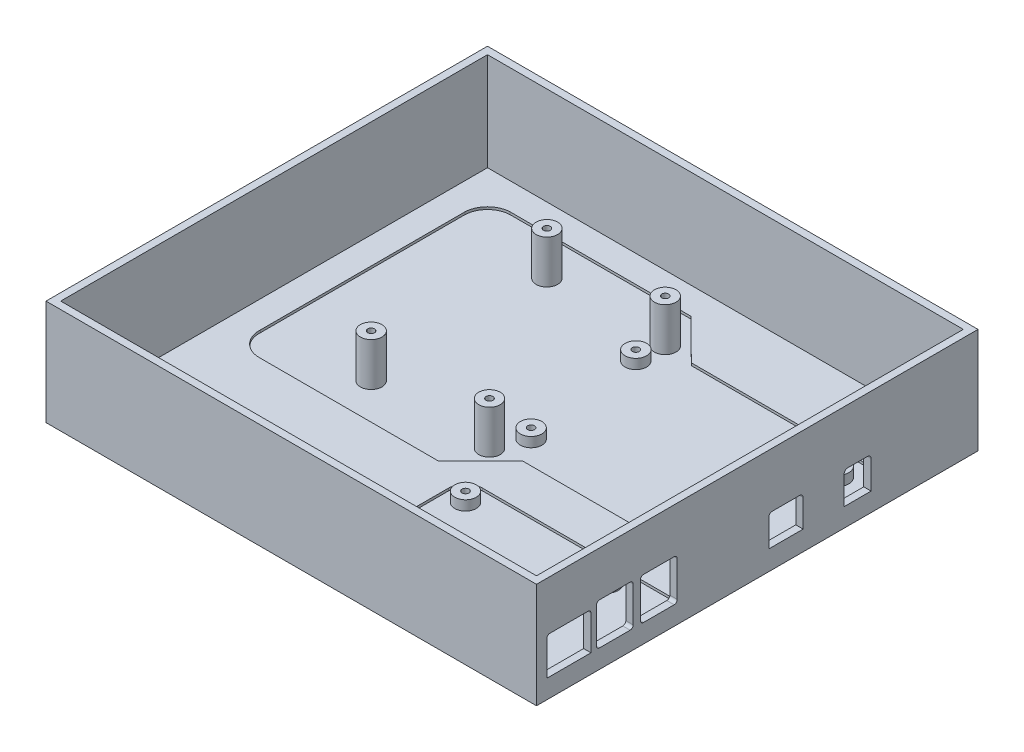
from build123d import *

# Parameters (mm, degrees)
SKETCH1_W           = 200.4
SKETCH1_H           = 180.383316975
SKETCH1_W_2         = 194.4
SKETCH1_H_2         = 174.383316975
BOSS_EXTRUDE1_DEPTH = 3
SKETCH1_3_W         = 200.4
SKETCH1_3_H         = 180.383316975
SKETCH1_3_W_2       = 194.4
SKETCH1_3_H_2       = 174.383316975
BOSS_EXTRUDE2_DEPTH = 40
SKETCH2_R           = 4.4
SKETCH2_R_2         = 1.4
BOSS_EXTRUDE3_DEPTH = 3
BOSS_EXTRUDE4_START = 3
SKETCH2_2_R         = 4.4
SKETCH2_2_R_2       = 1.4
BOSS_EXTRUDE4_DEPTH = 13.67
SKETCH3_R           = 4.4
CUT_EXTRUDE1_DEPTH  = 1
CUT_EXTRUDE2_DEPTH  = 5


with BuildPart() as part:
    # Sketch1 → Boss-Extrude1 (new body)
    with BuildSketch(Plane(origin=(0, -4, 0), x_dir=(-1, 0, 0), z_dir=(0, -1, 0))):
        with Locations((47.125, -25.608341513)):
            Rectangle(SKETCH1_W, SKETCH1_H)
        with Locations((47.125, -25.608341513)):
            Rectangle(SKETCH1_W_2, SKETCH1_H_2, mode=Mode.SUBTRACT)
        with Locations((47.125, -25.608341513)):
            Rectangle(SKETCH1_W_2, SKETCH1_H_2)
    extrude(amount=BOSS_EXTRUDE1_DEPTH)

    # Sketch1_3 → Boss-Extrude2 (add)
    with BuildSketch(Plane(origin=(0, -4, 0), x_dir=(-1, 0, 0), z_dir=(0, -1, 0))):
        with Locations((47.125, -25.608341513)):
            Rectangle(SKETCH1_3_W, SKETCH1_3_H)
        with Locations((47.125, -25.608341513)):
            Rectangle(SKETCH1_3_W_2, SKETCH1_3_H_2, mode=Mode.SUBTRACT)
    extrude(amount=-BOSS_EXTRUDE2_DEPTH)

    # Sketch2 → Boss-Extrude3 (add)
    with BuildSketch(Plane(origin=(0, -4, 0), x_dir=(1, 0, 0), z_dir=(0, 1, 0))):
        with Locations(Location((-94.083642028, 35.599553337, 0), (0, 0, 90))):
            Circle(SKETCH2_R)
        with Locations(Location((-94.083642028, 35.599553337, 0), (0, 0, 270))):
            Circle(SKETCH2_R_2, mode=Mode.SUBTRACT)
        with Locations(Location((-45.977533902, 35.843746779, 0), (0, 0, 90))):
            Circle(SKETCH2_R)
        with Locations(Location((-45.977533902, 35.843746779, 0), (0, 0, 270))):
            Circle(SKETCH2_R_2, mode=Mode.SUBTRACT)
        with Locations(Location((-46.675, 24.55, 0), (0, 0, 90))):
            Circle(SKETCH2_R)
        with Locations(Location((-46.675, 24.55, 0), (0, 0, 270))):
            Circle(SKETCH2_R_2, mode=Mode.SUBTRACT)
        with Locations(Location((35.975, 24.55, 0), (0, 0, 90))):
            Circle(SKETCH2_R)
        with Locations(Location((35.975, 24.55, 0), (0, 0, 270))):
            Circle(SKETCH2_R_2, mode=Mode.SUBTRACT)
        with Locations(Location((-40.425, -24.5, 0), (0, 0, 90))):
            Circle(SKETCH2_R)
        with Locations(Location((-40.425, -24.5, 0), (0, 0, 270))):
            Circle(SKETCH2_R_2, mode=Mode.SUBTRACT)
        with Locations(Location((-93.717351865, -36.559608852, 0), (0, 0, 90))):
            Circle(SKETCH2_R)
        with Locations(Location((-93.717351865, -36.559608852, 0), (0, 0, 270))):
            Circle(SKETCH2_R_2, mode=Mode.SUBTRACT)
        with Locations(Location((-45.611243739, -36.31541541, 0), (0, 0, 90))):
            Circle(SKETCH2_R)
        with Locations(Location((-45.611243739, -36.31541541, 0), (0, 0, 270))):
            Circle(SKETCH2_R_2, mode=Mode.SUBTRACT)
        with Locations(Location((34.775, -24.5, 0), (0, 0, 90))):
            Circle(SKETCH2_R)
        with Locations(Location((34.775, -24.5, 0), (0, 0, 270))):
            Circle(SKETCH2_R_2, mode=Mode.SUBTRACT)
        with Locations(Location((-31.425, -60.3, 0), (0, 0, 90))):
            Circle(SKETCH2_R)
        with Locations(Location((-31.425, -60.3, 0), (0, 0, 270))):
            Circle(SKETCH2_R_2, mode=Mode.SUBTRACT)
        with Locations(Location((26.575, -60.3, 0), (0, 0, 90))):
            Circle(SKETCH2_R)
        with Locations(Location((26.575, -60.3, 0), (0, 0, 270))):
            Circle(SKETCH2_R_2, mode=Mode.SUBTRACT)
        with Locations((-31.425, -109.3)):
            Circle(SKETCH2_R)
        with Locations(Location((-31.425, -109.3, 0), (0, 0, 270))):
            Circle(SKETCH2_R_2, mode=Mode.SUBTRACT)
        with Locations((26.575, -109.3)):
            Circle(SKETCH2_R)
        with Locations(Location((26.575, -109.3, 0), (0, 0, 270))):
            Circle(SKETCH2_R_2, mode=Mode.SUBTRACT)
    extrude(amount=BOSS_EXTRUDE3_DEPTH)

    # Sketch2_2 → Boss-Extrude4 (add)
    with BuildSketch(Plane(origin=(0, -4, 0), x_dir=(1, 0, 0), z_dir=(0, 1, 0)).offset(BOSS_EXTRUDE4_START)):
        with Locations(Location((-93.717351865, -36.559608852, 0), (0, 0, 90))):
            Circle(SKETCH2_2_R)
        with Locations(Location((-93.717351865, -36.559608852, 0), (0, 0, 270))):
            Circle(SKETCH2_2_R_2, mode=Mode.SUBTRACT)
        with Locations(Location((-45.611243739, -36.31541541, 0), (0, 0, 90))):
            Circle(SKETCH2_2_R)
        with Locations(Location((-45.611243739, -36.31541541, 0), (0, 0, 270))):
            Circle(SKETCH2_2_R_2, mode=Mode.SUBTRACT)
        with Locations(Location((-45.977533902, 35.843746779, 0), (0, 0, 90))):
            Circle(SKETCH2_2_R)
        with Locations(Location((-45.977533902, 35.843746779, 0), (0, 0, 270))):
            Circle(SKETCH2_2_R_2, mode=Mode.SUBTRACT)
        with Locations(Location((-94.083642028, 35.599553337, 0), (0, 0, 90))):
            Circle(SKETCH2_2_R)
        with Locations(Location((-94.083642028, 35.599553337, 0), (0, 0, 270))):
            Circle(SKETCH2_2_R_2, mode=Mode.SUBTRACT)
    extrude(amount=BOSS_EXTRUDE4_DEPTH)

    # Sketch3 → Cut-Extrude1 (cut)
    with BuildSketch(Plane(origin=(0, -4, 0), x_dir=(1, 0, 0), z_dir=(0, 1, 0))):
        with BuildLine():
            ThreePointArc((-133.325, -42.184637589), (-130.587997755, -49.351043774), (-123.472052941, -52.216683025))
            Line((-123.472052941, -52.216683025), (-50.730015352, -52.216683025))
            Line((-50.730015352, -52.216683025), (-33.377368591, -35.013077971))
            Line((-33.377368591, -35.013077971), (40.937843176, -35.013077971))
            ThreePointArc((40.937843176, -35.013077971), (46.610387698, -33.142667164), (50.075, -28.277211426))
            Line((50.075, -28.277211426), (50.075, 27.447920543))
            ThreePointArc((50.075, 27.447920543), (46.449358415, 32.437948869), (40.534398357, 34.186922029))
            Line((40.534398357, 34.186922029), (-33.678452679, 34.186922029))
            Line((-33.678452679, 34.186922029), (-50.108918246, 50.583316975))
            Line((-50.108918246, 50.583316975), (-124.102104511, 50.583316975))
            ThreePointArc((-124.102104511, 50.583316975), (-130.528855148, 47.775760881), (-133.325, 41.344037245))
            Line((-133.325, 41.344037245), (-133.325, -42.184637589))
        make_face()
        with Locations(Location((-93.717351865, -36.559608852, 0), (0, 0, 270))):
            Circle(SKETCH3_R, mode=Mode.SUBTRACT)
        with Locations(Location((-45.611243739, -36.31541541, 0), (0, 0, 270))):
            Circle(SKETCH3_R, mode=Mode.SUBTRACT)
        with Locations(Location((-94.083642028, 35.599553337, 0), (0, 0, 270))):
            Circle(SKETCH3_R, mode=Mode.SUBTRACT)
        with Locations(Location((-40.425, -24.5, 0), (0, 0, 270))):
            Circle(SKETCH3_R, mode=Mode.SUBTRACT)
        with Locations(Location((34.775, -24.5, 0), (0, 0, 270))):
            Circle(SKETCH3_R, mode=Mode.SUBTRACT)
        with Locations(Location((-46.675, 24.55, 0), (0, 0, 270))):
            Circle(SKETCH3_R, mode=Mode.SUBTRACT)
        with Locations(Location((-45.977533902, 35.843746779, 0), (0, 0, 270))):
            Circle(SKETCH3_R, mode=Mode.SUBTRACT)
        with Locations(Location((35.975, 24.55, 0), (0, 0, 270))):
            Circle(SKETCH3_R, mode=Mode.SUBTRACT)
        with BuildLine():
            Line((50.075, -112.8), (50.075, -53.47544468))
            ThreePointArc((50.075, -53.47544468), (48.612548822, -52.970948556), (47.075, -52.8))
            Line((47.075, -52.8), (-31.925, -52.8))
            ThreePointArc((-31.925, -52.8), (-36.874747468, -54.850252532), (-38.925, -59.8))
            Line((-38.925, -59.8), (-38.925, -109.8))
            ThreePointArc((-38.925, -109.8), (-38.754051444, -111.337548822), (-38.24955532, -112.8))
            Line((-38.24955532, -112.8), (-34.091458325, -112.8))
            ThreePointArc((-34.091458325, -112.8), (-31.425, -104.9), (-28.758541675, -112.8))
            Line((-28.758541675, -112.8), (23.908541675, -112.8))
            ThreePointArc((23.908541675, -112.8), (26.575, -104.9), (29.241458325, -112.8))
            Line((29.241458325, -112.8), (50.075, -112.8))
        make_face()
        with Locations(Location((-31.425, -60.3, 0), (0, 0, 270))):
            Circle(SKETCH3_R, mode=Mode.SUBTRACT)
        with Locations(Location((26.575, -60.3, 0), (0, 0, 270))):
            Circle(SKETCH3_R, mode=Mode.SUBTRACT)
    extrude(amount=-CUT_EXTRUDE1_DEPTH, mode=Mode.SUBTRACT)

    # Sketch4 → Cut-Extrude2 (cut)
    with BuildSketch(Plane(origin=(53.075, 0, 0), x_dir=(0, 0, -1), z_dir=(1, 0, 0))):
        with BuildLine():
            Line((9.9, 0.63), (20.9, 0.63))
            Line((20.9, 0.63), (20.9, 12.13))
            ThreePointArc((20.9, 12.13), (20.460660172, 13.190660172), (19.4, 13.63))
            Line((19.4, 13.63), (11.4, 13.63))
            ThreePointArc((11.4, 13.63), (10.339339828, 13.190660172), (9.9, 12.13))
            Line((9.9, 12.13), (9.9, 0.63))
        make_face()
        with BuildLine():
            Line((-8.32, 13.68), (-19.44, 13.68))
            ThreePointArc((-19.44, 13.68), (-20.472375901, 13.252375901), (-20.9, 12.22))
            Line((-20.9, 12.22), (-20.9, 12.12))
            Line((-20.9, 12.12), (-20.9, 2.47))
            Line((-20.9, 2.47), (-20.9, 1.06))
            Line((-20.9, 1.06), (-6.86, 1.06))
            Line((-6.86, 1.06), (-6.86, 2.47))
            Line((-6.86, 2.47), (-6.86, 12.12))
            Line((-6.86, 12.12), (-6.86, 12.22))
            ThreePointArc((-6.86, 12.22), (-7.287624099, 13.252375901), (-8.32, 13.68))
        make_face()
        with BuildLine():
            Line((-71.3, 17.63), (-60.3, 17.63))
            Line((-60.3, 17.63), (-59.55, 17.63))
            ThreePointArc((-59.55, 17.63), (-58.990983006, 17.498033989), (-58.55, 17.13))
            ThreePointArc((-58.55, 17.13), (-58.364145877, 16.775284708), (-58.3, 16.38))
            Line((-58.3, 16.38), (-58.3, 15.13))
            Line((-58.3, 15.13), (-58.3, 3.13))
            Line((-58.3, 3.13), (-58.3, 1.88))
            ThreePointArc((-58.3, 1.88), (-58.364145877, 1.484715292), (-58.55, 1.13))
            ThreePointArc((-58.55, 1.13), (-58.990983006, 0.761966011), (-59.55, 0.63))
            Line((-59.55, 0.63), (-60.3, 0.63))
            Line((-60.3, 0.63), (-71.3, 0.63))
            Line((-71.3, 0.63), (-72.05, 0.63))
            ThreePointArc((-72.05, 0.63), (-72.609016994, 0.761966011), (-73.05, 1.13))
            ThreePointArc((-73.05, 1.13), (-73.235854123, 1.484715292), (-73.3, 1.88))
            Line((-73.3, 1.88), (-73.3, 3.13))
            Line((-73.3, 3.13), (-73.3, 15.13))
            Line((-73.3, 15.13), (-73.3, 16.38))
            ThreePointArc((-73.3, 16.38), (-73.235854123, 16.775284708), (-73.05, 17.13))
            ThreePointArc((-73.05, 17.13), (-72.609016994, 17.498033989), (-72.05, 17.63))
            Line((-72.05, 17.63), (-71.3, 17.63))
        make_face()
        with BuildLine():
            Line((-90.05, 0.63), (-89.3, 0.63))
            Line((-89.3, 0.63), (-78.3, 0.63))
            Line((-78.3, 0.63), (-77.55, 0.63))
            ThreePointArc((-77.55, 0.63), (-76.990983006, 0.761966011), (-76.55, 1.13))
            ThreePointArc((-76.55, 1.13), (-76.364145877, 1.484715292), (-76.3, 1.88))
            Line((-76.3, 1.88), (-76.3, 3.13))
            Line((-76.3, 3.13), (-76.3, 15.13))
            Line((-76.3, 15.13), (-76.3, 16.38))
            ThreePointArc((-76.3, 16.38), (-76.364145877, 16.775284708), (-76.55, 17.13))
            ThreePointArc((-76.55, 17.13), (-76.990983006, 17.498033989), (-77.55, 17.63))
            Line((-77.55, 17.63), (-78.3, 17.63))
            Line((-78.3, 17.63), (-89.3, 17.63))
            Line((-89.3, 17.63), (-90.05, 17.63))
            ThreePointArc((-90.05, 17.63), (-90.609016994, 17.498033989), (-91.05, 17.13))
            ThreePointArc((-91.05, 17.13), (-91.235854123, 16.775284708), (-91.3, 16.38))
            Line((-91.3, 16.38), (-91.3, 15.13))
            Line((-91.3, 15.13), (-91.3, 3.13))
            Line((-91.3, 3.13), (-91.3, 1.88))
            ThreePointArc((-91.3, 1.88), (-91.235854123, 1.484715292), (-91.05, 1.13))
            ThreePointArc((-91.05, 1.13), (-90.609016994, 0.761966011), (-90.05, 0.63))
        make_face()
        with BuildLine():
            Line((-93.55, 14.73), (-93.55, 1.63))
            Line((-93.55, 1.63), (-93.55, 0.63))
            Line((-93.55, 0.63), (-100.55, 0.63))
            Line((-100.55, 0.63), (-104.55, 0.63))
            Line((-104.55, 0.63), (-111.55, 0.63))
            Line((-111.55, 0.63), (-111.55, 1.63))
            Line((-111.55, 1.63), (-111.55, 14.73))
            ThreePointArc((-111.55, 14.73), (-111.198528137, 15.578528137), (-110.35, 15.93))
            Line((-110.35, 15.93), (-94.75, 15.93))
            ThreePointArc((-94.75, 15.93), (-93.901471863, 15.578528137), (-93.55, 14.73))
        make_face()
    extrude(amount=-CUT_EXTRUDE2_DEPTH, mode=Mode.SUBTRACT)


solid = part.part
